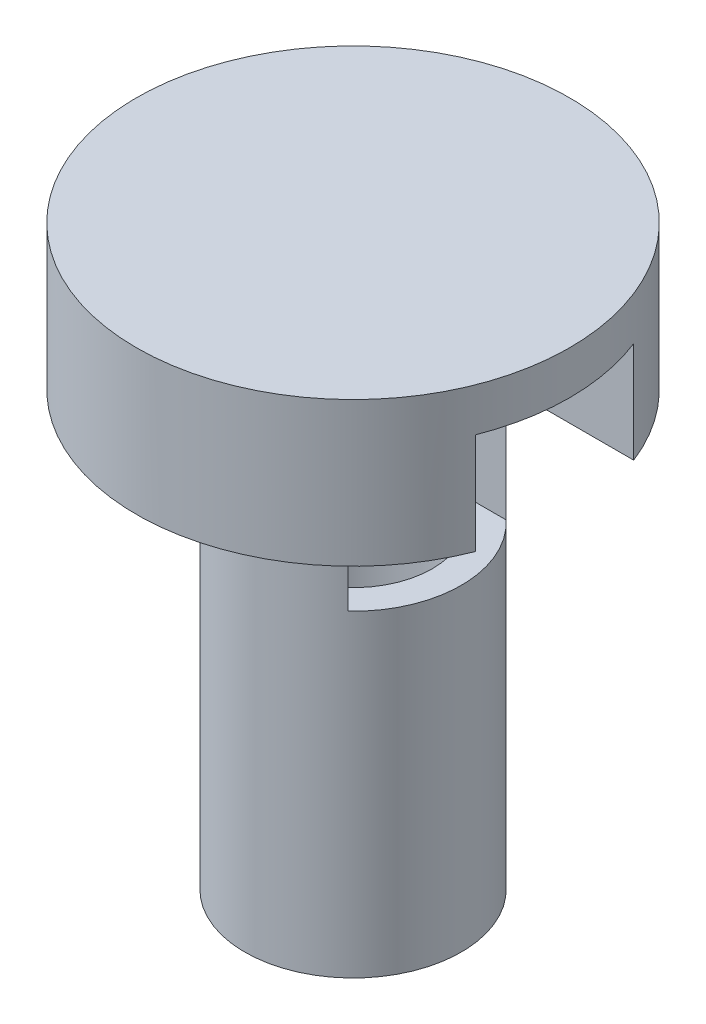
from build123d import *

# Parameters (mm, degrees)
SKETCH1_R           = 19.05
BOSS_EXTRUDE1_DEPTH = 12.7
SKETCH2_R           = 9.525
BOSS_EXTRUDE2_DEPTH = 38.1
SKETCH3_R           = 6.985
CUT_EXTRUDE1_DEPTH  = 46.99
CUT_EXTRUDE2_DEPTH  = 19.05


with BuildPart() as part:
    # Sketch1 → Boss-Extrude1 (new body)
    with BuildSketch(Plane(origin=(0, 0, 0), x_dir=(1, 0, 0), z_dir=(0, 1, 0))):
        Circle(SKETCH1_R)
    extrude(amount=BOSS_EXTRUDE1_DEPTH)

    # Sketch2 → Boss-Extrude2 (add)
    with BuildSketch(Plane.XZ):
        Circle(SKETCH2_R)
    extrude(amount=BOSS_EXTRUDE2_DEPTH)

    # Sketch3 → Cut-Extrude1 (cut)
    with BuildSketch(Plane.XZ.offset(38.1)):
        Circle(SKETCH3_R)
    extrude(amount=-CUT_EXTRUDE1_DEPTH, mode=Mode.SUBTRACT)

    # Sketch5 → Cut-Extrude2 (cut)
    with BuildSketch(Plane.XZ.offset(-8.89)):
        with BuildLine():
            Line((0, 6.957071705), (19.05, 6.957071705))
            ThreePointArc((19.05, 6.957071705), (26.007071705, 0), (19.05, -6.957071705))
            Line((19.05, -6.957071705), (0, -6.957071705))
            ThreePointArc((0, -6.957071705), (-6.957071705, 0), (0, 6.957071705))
        make_face()
    extrude(amount=CUT_EXTRUDE2_DEPTH, mode=Mode.SUBTRACT)


solid = part.part
